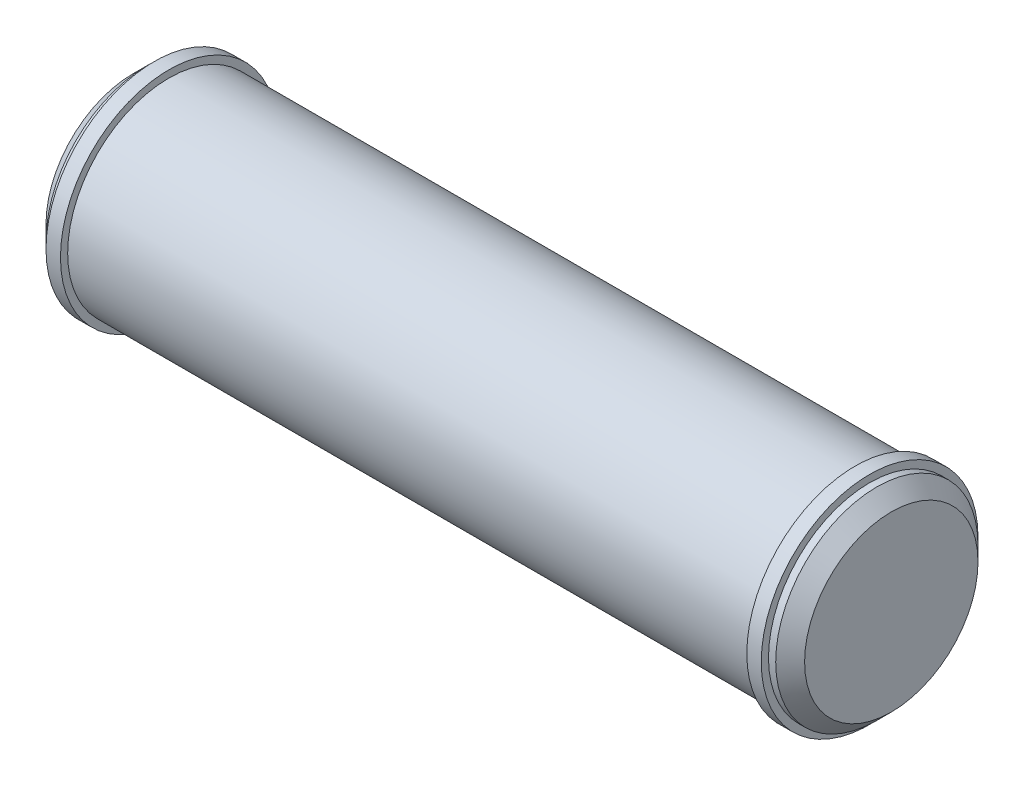
from build123d import *


with BuildPart() as part:
    # Sketch1 → Revolve3 (revolve)
    with BuildSketch(Plane.XY):
        Polygon((-52.5, 0), (52.5, 0), (52.5, 12), (50.5, 14), (49.5, 14), (49.5, 15), (47.5, 15), (47.5, 14), (-47.5, 14), (-47.5, 15), (-49.5, 15), (-49.5, 14), (-50.5, 14), (-52.5, 12), align=None)
    revolve(axis=Axis((-632.820263968, 0, 0), (1, 0, 0)))


solid = part.part
